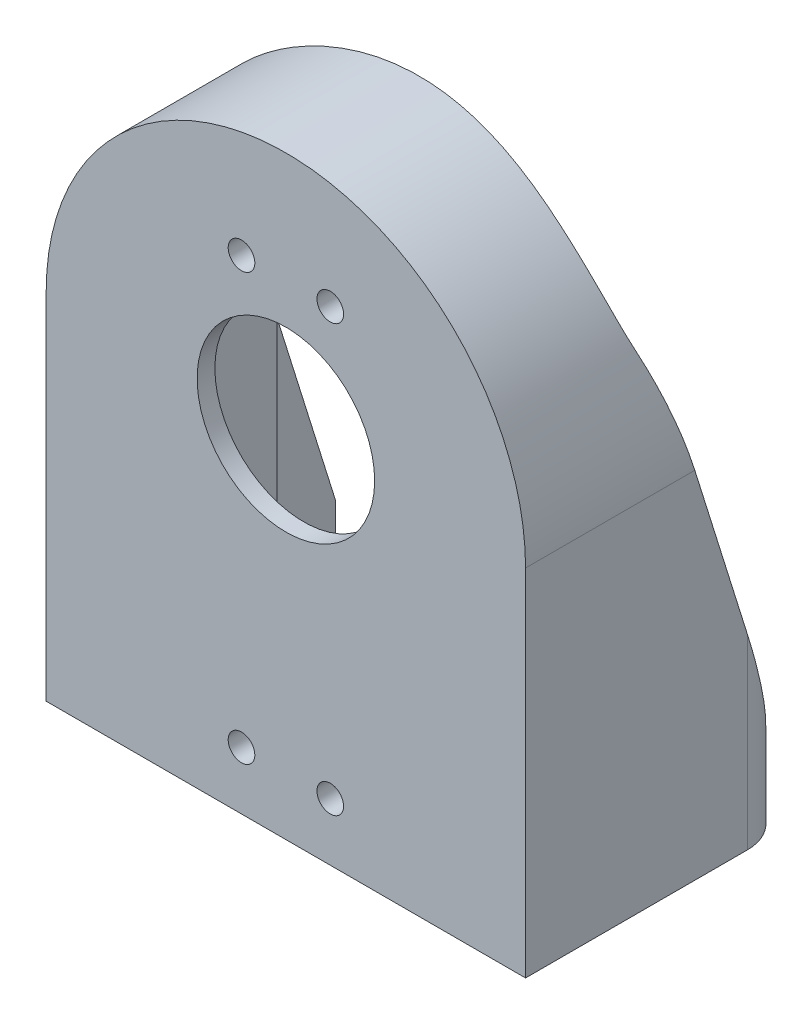
from build123d import *

# Parameters (mm, degrees)
BOSS_EXTRUDE1_DEPTH     = 30
SKETCH3_4_R             = 10
BOSS_EXTRUDE2_DEPTH     = 10
SKETCH4_R               = 1.5
SKETCH4_R_2             = 2
CUT_EXTRUDE1_DEPTH      = 10
CUT_EXTRUDE2_DEPTH      = 62.951594007
CUT_EXTRUDE2_DEPTH_BACK = 62.951594007
CUT_EXTRUDE3_START      = -8
SKETCH6_W               = 22
SKETCH6_H               = 41
SKETCH6_R               = 10
CUT_EXTRUDE3_DEPTH      = 8
SKETCH6_3_R             = 1.5
CUT_EXTRUDE4_DEPTH      = 58.775427431
CUT_EXTRUDE5_DEPTH      = 79.217645188


with BuildPart() as part:
    # Sketch3 → Boss-Extrude1 (new body)
    with BuildSketch(Plane.XY):
        with BuildLine():
            Line((-27, 20), (-27, -20))
            Line((-27, -20), (27, -20))
            Line((27, -20), (27, 20))
            ThreePointArc((27, 20), (0, 47), (-27, 20))
        make_face()
        with BuildLine():
            Line((24, -17), (-24, -17))
            Line((-24, -17), (-24, 20))
            ThreePointArc((-24, 20), (0, 44), (24, 20))
            Line((24, 20), (24, -17))
        make_face(mode=Mode.SUBTRACT)
    extrude(amount=-BOSS_EXTRUDE1_DEPTH)

    # Sketch3_4 → Boss-Extrude2 (add)
    with BuildSketch(Plane.XY):
        with BuildLine():
            Line((-24, 20), (-24, -17))
            Line((-24, -17), (24, -17))
            Line((24, -17), (24, 20))
            ThreePointArc((24, 20), (0, 44), (-24, 20))
        make_face()
        with Locations((0, 20)):
            Circle(SKETCH3_4_R, mode=Mode.SUBTRACT)
    extrude(amount=-BOSS_EXTRUDE2_DEPTH)

    # Sketch4 → Cut-Extrude1 (cut)
    with BuildSketch(Plane.XZ.offset(20)):
        with Locations((3, -15)):
            Circle(SKETCH4_R)
        with Locations((17, -15)):
            Circle(SKETCH4_R)
        with Locations((10, -15)):
            Circle(SKETCH4_R_2)
    extrude(amount=-CUT_EXTRUDE1_DEPTH, mode=Mode.SUBTRACT)

    # Sketch5 → Cut-Extrude2 (cut, two sides: drawn at the far end of the back side and taken through both)
    with BuildSketch(Plane(origin=(0, 0, 0), x_dir=(0, 0, -1), z_dir=(1, 0, 0)).offset(-CUT_EXTRUDE2_DEPTH_BACK)):
        with BuildLine():
            Line((15.255034443, 32.183889783), (30, -15))
            Line((30, -15), (30, 47))
            Line((30, 47), (15, 47))
            ThreePointArc((15, 47), (14.181044165, 40.740478791), (14.690093427, 34.448168938))
            ThreePointArc((14.690093427, 34.448168938), (14.93950997, 33.307782347), (15.255034443, 32.183889783))
        make_face()
    extrude(amount=CUT_EXTRUDE2_DEPTH + CUT_EXTRUDE2_DEPTH_BACK, mode=Mode.SUBTRACT)

    # Sketch6 → Cut-Extrude3 (cut)
    with BuildSketch(Plane(origin=(0, 0, -10), x_dir=(-1, 0, 0), z_dir=(0, 0, -1)).offset(CUT_EXTRUDE3_START)):
        with Locations((0, 10.5)):
            Rectangle(SKETCH6_W, SKETCH6_H)
        with Locations((0, 20)):
            Circle(SKETCH6_R, mode=Mode.SUBTRACT)
    extrude(amount=CUT_EXTRUDE3_DEPTH, mode=Mode.SUBTRACT)

    # Sketch6_3 → Cut-Extrude4 (cut, through all)
    with BuildSketch(Plane(origin=(0, 0, -10), x_dir=(-1, 0, 0), z_dir=(0, 0, -1))):
        with Locations((-5, 34.5)):
            Circle(SKETCH6_3_R)
        with Locations((5, 34.5)):
            Circle(SKETCH6_3_R)
        with Locations((5, -13.5)):
            Circle(SKETCH6_3_R)
        with Locations((-5, -13.5)):
            Circle(SKETCH6_3_R)
    extrude(amount=-CUT_EXTRUDE4_DEPTH, mode=Mode.SUBTRACT)

    # Sketch7 → Cut-Extrude5 (cut, through all)
    with BuildSketch(Plane.XZ.offset(20)):
        with BuildLine():
            Line((-27, -25), (-27, -30))
            Line((-27, -30), (-22, -30))
            ThreePointArc((-22, -30), (-25.535533906, -28.535533906), (-27, -25))
        make_face()
        with BuildLine():
            Line((22, -30), (27, -30))
            Line((27, -30), (27, -25))
            ThreePointArc((27, -25), (25.535533906, -28.535533906), (22, -30))
        make_face()
    extrude(amount=-CUT_EXTRUDE5_DEPTH, mode=Mode.SUBTRACT)


solid = part.part
